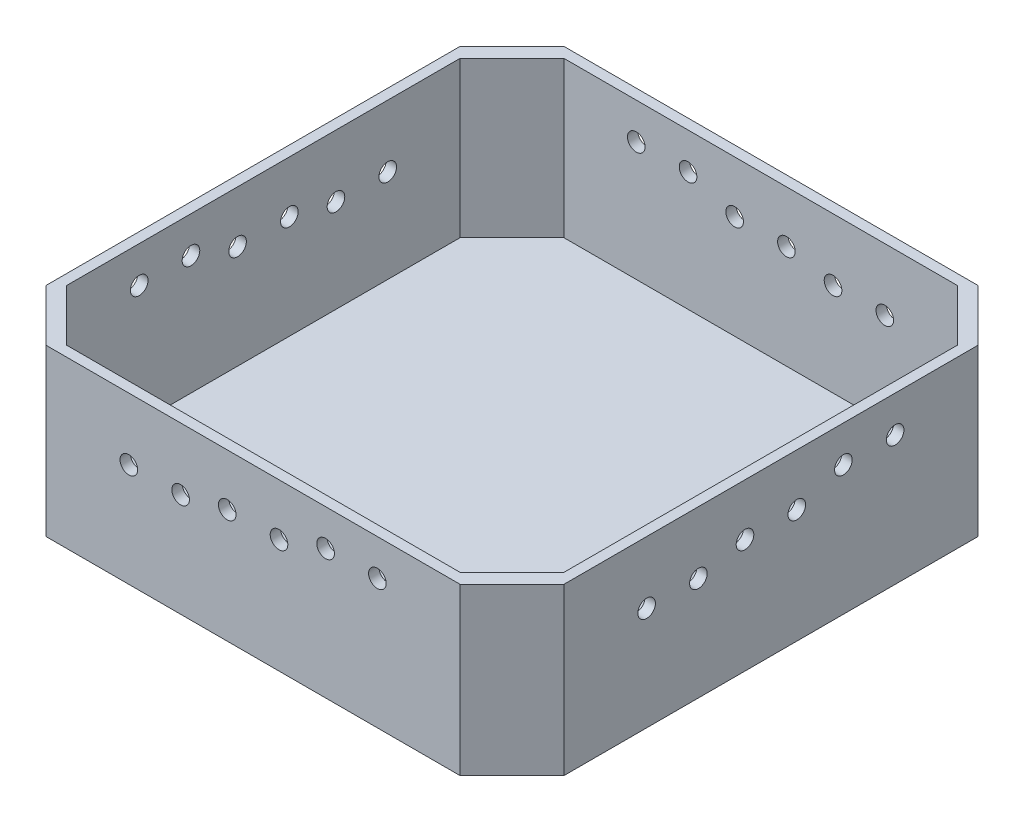
from build123d import *

# Parameters (mm, degrees)
SKETCH1_W                     = 100
SKETCH1_H                     = 100
BOSS_EXTRUDE1_DEPTH           = 2
SKETCH2_W                     = 100
SKETCH2_H                     = 100
SKETCH2_W_2                   = 96
SKETCH2_H_2                   = 96
BOSS_EXTRUDE2_DEPTH           = 30
CHAMFER1_SIZE                 = 10
M3_CLEARANCE_HOLE1_AT_2_COUNT = 2
M3_CLEARANCE_HOLE1_AT_2_PITCH = 10
M3_CLEARANCE_HOLE1_AT_3_COUNT = 2
M3_CLEARANCE_HOLE1_AT_3_PITCH = 19.235384062
M3_CLEARANCE_HOLE1_AT_4_COUNT = 2
M3_CLEARANCE_HOLE1_AT_4_PITCH = 29.154759474
M3_CLEARANCE_HOLE1_AT_5_COUNT = 2
M3_CLEARANCE_HOLE1_AT_5_PITCH = 38.327535793
M3_CLEARANCE_HOLE1_AT_6_COUNT = 2
M3_CLEARANCE_HOLE1_AT_6_PITCH = 48.259714048
CIRPATTERN1_COUNT             = 4


with BuildPart() as part:
    # Sketch1 → Boss-Extrude1 (new body)
    with BuildSketch(Plane(origin=(0, 0, 0), x_dir=(1, 0, 0), z_dir=(0, 1, 0))):
        Rectangle(SKETCH1_W, SKETCH1_H)
    extrude(amount=BOSS_EXTRUDE1_DEPTH)

    # Sketch2 → Boss-Extrude2 (add)
    with BuildSketch(Plane(origin=(0, 2, 0), x_dir=(1, 0, 0), z_dir=(0, 1, 0))):
        Rectangle(SKETCH2_W, SKETCH2_H)
        Rectangle(SKETCH2_W_2, SKETCH2_H_2, mode=Mode.SUBTRACT)
    extrude(amount=BOSS_EXTRUDE2_DEPTH)

    # Chamfer1
    chamfer1_edges = [part.edges().sort_by_distance(p)[0] for p in [
        (-48, 17, -48),
        (-48, 17, 48),
        (48, 17, 48),
        (48, 17, -48),
        (-50, 16, -50),
        (50, 16, -50),
        (50, 16, 50),
        (-50, 16, 50),
    ]]
    chamfer(chamfer1_edges, length=CHAMFER1_SIZE)

    # Sketch3 → M3 Clearance Hole1 (revolve, cut)
    with BuildSketch(Plane(origin=(-24, 25, -48), x_dir=(0, -1, 0), z_dir=(1, 0, 0))):
        Polygon((0, 0), (0, 6.021463052), (1.7, 5), (1.7, 0), align=None)
    m3_clearance_hole1 = revolve(axis=Axis((-24, 25, -41.65), (0, 0, -1)), mode=Mode.SUBTRACT)

    # M3 Clearance Hole1 at 2: M3 Clearance Hole1 ×2
    with Locations(*[(i * M3_CLEARANCE_HOLE1_AT_2_PITCH, 0, 0) for i in range(1, M3_CLEARANCE_HOLE1_AT_2_COUNT)]):
        add(m3_clearance_hole1, mode=Mode.SUBTRACT)

    # M3 Clearance Hole1 at 3: M3 Clearance Hole1 ×2
    with Locations(*[Vector(0.987762965, -0.155962573, 0) * (i * M3_CLEARANCE_HOLE1_AT_3_PITCH) for i in range(1, M3_CLEARANCE_HOLE1_AT_3_COUNT)]):
        add(m3_clearance_hole1, mode=Mode.SUBTRACT)

    # M3 Clearance Hole1 at 4: M3 Clearance Hole1 ×2
    with Locations(*[Vector(0.994691794, -0.102899151, 0) * (i * M3_CLEARANCE_HOLE1_AT_4_PITCH) for i in range(1, M3_CLEARANCE_HOLE1_AT_4_COUNT)]):
        add(m3_clearance_hole1, mode=Mode.SUBTRACT)

    # M3 Clearance Hole1 at 5: M3 Clearance Hole1 ×2
    with Locations(*[Vector(0.991454296, -0.130454513, 0) * (i * M3_CLEARANCE_HOLE1_AT_5_PITCH) for i in range(1, M3_CLEARANCE_HOLE1_AT_5_COUNT)]):
        add(m3_clearance_hole1, mode=Mode.SUBTRACT)

    # M3 Clearance Hole1 at 6: M3 Clearance Hole1 ×2
    with Locations(*[Vector(0.994618409, -0.103606084, 0) * (i * M3_CLEARANCE_HOLE1_AT_6_PITCH) for i in range(1, M3_CLEARANCE_HOLE1_AT_6_COUNT)]):
        add(m3_clearance_hole1, mode=Mode.SUBTRACT)

    # CirPattern1: M3 Clearance Hole1 ×4 about axis
    cirpattern1_axis = Axis((0, 50, 0), (0, -1, 0))
    for i in range(1, CIRPATTERN1_COUNT):
        add(m3_clearance_hole1.rotate(cirpattern1_axis, i * 360 / CIRPATTERN1_COUNT), mode=Mode.SUBTRACT)

    # CirPattern1 copy 1 sketch → CirPattern1 copy 1 (revolve, cut)
    with BuildSketch(Plane(origin=(48, 25, -14), x_dir=(0, -1, 0), z_dir=(0, 0, 1))):
        Polygon((0, 0), (0, 6.021463052), (1.7, 5), (1.7, 0), align=None)
    revolve(axis=Axis((41.65, 25, -14), (1, 0, 0)), mode=Mode.SUBTRACT)

    # CirPattern1 copy 2 sketch → CirPattern1 copy 2 (revolve, cut)
    with BuildSketch(Plane(origin=(14, 25, 48), x_dir=(0, -1, 0), z_dir=(-1, 0, 0))):
        Polygon((0, 0), (0, 6.021463052), (1.7, 5), (1.7, 0), align=None)
    revolve(axis=Axis((14, 25, 41.65), (0, 0, 1)), mode=Mode.SUBTRACT)

    # CirPattern1 copy 3 sketch → CirPattern1 copy 3 (revolve, cut)
    with BuildSketch(Plane(origin=(-48, 25, 14), x_dir=(0, -1, 0), z_dir=(0, 0, -1))):
        Polygon((0, 0), (0, 6.021463052), (1.7, 5), (1.7, 0), align=None)
    revolve(axis=Axis((-41.65, 25, 14), (-1, 0, 0)), mode=Mode.SUBTRACT)

    # CirPattern1 copy 4 sketch → CirPattern1 copy 4 (revolve, cut)
    with BuildSketch(Plane(origin=(48, 22, -5), x_dir=(0, -1, 0), z_dir=(0, 0, 1))):
        Polygon((0, 0), (0, 6.021463052), (1.7, 5), (1.7, 0), align=None)
    revolve(axis=Axis((41.65, 22, -5), (1, 0, 0)), mode=Mode.SUBTRACT)

    # CirPattern1 copy 5 sketch → CirPattern1 copy 5 (revolve, cut)
    with BuildSketch(Plane(origin=(5, 22, 48), x_dir=(0, -1, 0), z_dir=(-1, 0, 0))):
        Polygon((0, 0), (0, 6.021463052), (1.7, 5), (1.7, 0), align=None)
    revolve(axis=Axis((5, 22, 41.65), (0, 0, 1)), mode=Mode.SUBTRACT)

    # CirPattern1 copy 6 sketch → CirPattern1 copy 6 (revolve, cut)
    with BuildSketch(Plane(origin=(-48, 22, 5), x_dir=(0, -1, 0), z_dir=(0, 0, -1))):
        Polygon((0, 0), (0, 6.021463052), (1.7, 5), (1.7, 0), align=None)
    revolve(axis=Axis((-41.65, 22, 5), (-1, 0, 0)), mode=Mode.SUBTRACT)

    # CirPattern1 copy 7 sketch → CirPattern1 copy 7 (revolve, cut)
    with BuildSketch(Plane(origin=(48, 22, 5), x_dir=(0, -1, 0), z_dir=(0, 0, 1))):
        Polygon((0, 0), (0, 6.021463052), (1.7, 5), (1.7, 0), align=None)
    revolve(axis=Axis((41.65, 22, 5), (1, 0, 0)), mode=Mode.SUBTRACT)

    # CirPattern1 copy 8 sketch → CirPattern1 copy 8 (revolve, cut)
    with BuildSketch(Plane(origin=(-5, 22, 48), x_dir=(0, -1, 0), z_dir=(-1, 0, 0))):
        Polygon((0, 0), (0, 6.021463052), (1.7, 5), (1.7, 0), align=None)
    revolve(axis=Axis((-5, 22, 41.65), (0, 0, 1)), mode=Mode.SUBTRACT)

    # CirPattern1 copy 9 sketch → CirPattern1 copy 9 (revolve, cut)
    with BuildSketch(Plane(origin=(-48, 22, -5), x_dir=(0, -1, 0), z_dir=(0, 0, -1))):
        Polygon((0, 0), (0, 6.021463052), (1.7, 5), (1.7, 0), align=None)
    revolve(axis=Axis((-41.65, 22, -5), (-1, 0, 0)), mode=Mode.SUBTRACT)

    # CirPattern1 copy 10 sketch → CirPattern1 copy 10 (revolve, cut)
    with BuildSketch(Plane(origin=(48, 20, 14), x_dir=(0, -1, 0), z_dir=(0, 0, 1))):
        Polygon((0, 0), (0, 6.021463052), (1.7, 5), (1.7, 0), align=None)
    revolve(axis=Axis((41.65, 20, 14), (1, 0, 0)), mode=Mode.SUBTRACT)

    # CirPattern1 copy 11 sketch → CirPattern1 copy 11 (revolve, cut)
    with BuildSketch(Plane(origin=(-14, 20, 48), x_dir=(0, -1, 0), z_dir=(-1, 0, 0))):
        Polygon((0, 0), (0, 6.021463052), (1.7, 5), (1.7, 0), align=None)
    revolve(axis=Axis((-14, 20, 41.65), (0, 0, 1)), mode=Mode.SUBTRACT)

    # CirPattern1 copy 12 sketch → CirPattern1 copy 12 (revolve, cut)
    with BuildSketch(Plane(origin=(-48, 20, -14), x_dir=(0, -1, 0), z_dir=(0, 0, -1))):
        Polygon((0, 0), (0, 6.021463052), (1.7, 5), (1.7, 0), align=None)
    revolve(axis=Axis((-41.65, 20, -14), (-1, 0, 0)), mode=Mode.SUBTRACT)

    # CirPattern1 copy 13 sketch → CirPattern1 copy 13 (revolve, cut)
    with BuildSketch(Plane(origin=(48, 20, 24), x_dir=(0, -1, 0), z_dir=(0, 0, 1))):
        Polygon((0, 0), (0, 6.021463052), (1.7, 5), (1.7, 0), align=None)
    revolve(axis=Axis((41.65, 20, 24), (1, 0, 0)), mode=Mode.SUBTRACT)

    # CirPattern1 copy 14 sketch → CirPattern1 copy 14 (revolve, cut)
    with BuildSketch(Plane(origin=(-24, 20, 48), x_dir=(0, -1, 0), z_dir=(-1, 0, 0))):
        Polygon((0, 0), (0, 6.021463052), (1.7, 5), (1.7, 0), align=None)
    revolve(axis=Axis((-24, 20, 41.65), (0, 0, 1)), mode=Mode.SUBTRACT)

    # CirPattern1 copy 15 sketch → CirPattern1 copy 15 (revolve, cut)
    with BuildSketch(Plane(origin=(-48, 20, -24), x_dir=(0, -1, 0), z_dir=(0, 0, -1))):
        Polygon((0, 0), (0, 6.021463052), (1.7, 5), (1.7, 0), align=None)
    revolve(axis=Axis((-41.65, 20, -24), (-1, 0, 0)), mode=Mode.SUBTRACT)


solid = part.part
